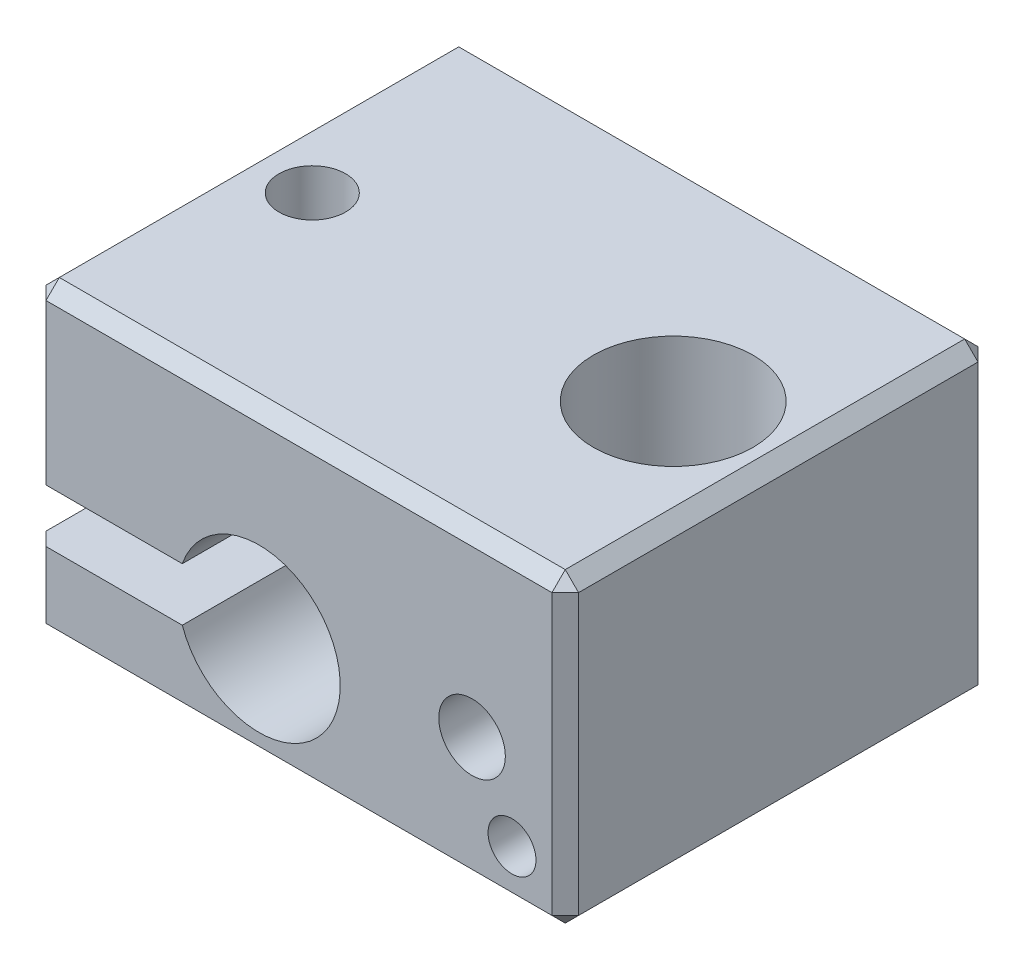
from build123d import *

# Parameters (mm, degrees)
BOSS_EXTRUDE1_DEPTH            = 8
CHAMFER1_SIZE                  = 0.5
M3X0_5_TAPPED_HOLE1_D          = 2.5
M3X0_5_TAPPED_HOLE1_DEPTH      = 3.5
M3X0_5_TAPPED_HOLE1_TIP        = 0.751075774
F_1_8_1_8_DIAMETER_HOLE1_D     = 1.8
F_1_8_1_8_DIAMETER_HOLE1_DEPTH = 2
F_1_8_1_8_DIAMETER_HOLE1_TIP   = 0.540774557
F_1_6_1_6_DIAMETER_HOLE1_D     = 1.6
F_1_6_1_6_DIAMETER_HOLE1_DEPTH = 4.5
F_1_6_1_6_DIAMETER_HOLE1_TIP   = 0.480688495
M3X0_5_TAPPED_HOLE2_D          = 2.5
M6X1_0_TAPPED_HOLE1_D          = 6


with BuildPart() as part:
    # Sketch1 → Boss-Extrude1 (new body, symmetric)
    with BuildSketch(Plane.XY):
        with BuildLine():
            Line((-10, -0.75), (-4.381405907, -0.75))
            ThreePointArc((-4.381405907, -0.75), (1.55, -1.75), (-4.381405907, -2.75))
            Line((-4.381405907, -2.75), (-10, -2.75))
            Line((-10, -2.75), (-10, -5.75))
            Line((-10, -5.75), (10, -5.75))
            Line((10, -5.75), (10, 5.75))
            Line((10, 5.75), (-10, 5.75))
            Line((-10, 5.75), (-10, -0.75))
        make_face()
    extrude(amount=BOSS_EXTRUDE1_DEPTH, both=True)

    # Chamfer1
    chamfer1_edges = [part.edges().sort_by_distance(p)[0] for p in [
        (-10, 2.5, 8),
        (0, 5.75, -8),
        (10, 0, -8),
        (10, -5.75, 0),
        (-10, -5.75, 0),
        (-10, 5.75, 0),
        (10, 5.75, 0),
        (-10, -4.25, 8),
        (0, -5.75, 8),
        (10, 0, 8),
        (0, 5.75, 8),
        (0, -5.75, -8),
        (-10, -4.25, -8),
        (-10, 2.5, -8),
    ]]
    chamfer(chamfer1_edges, length=CHAMFER1_SIZE)

    # M3x0.5 Tapped Hole1
    with Locations(Plane.XY.offset(8)):
        with Locations((6.5, -0.95)):
            Hole(M3X0_5_TAPPED_HOLE1_D / 2, depth=M3X0_5_TAPPED_HOLE1_DEPTH)
            with Locations((0, 0, -(M3X0_5_TAPPED_HOLE1_DEPTH + M3X0_5_TAPPED_HOLE1_TIP / 2))):  # 118° drill point
                Cone(0, M3X0_5_TAPPED_HOLE1_D / 2, M3X0_5_TAPPED_HOLE1_TIP, mode=Mode.SUBTRACT)

    # Ø1.8 (1.8) Diameter Hole1
    with Locations(Plane.XY.offset(8)):
        with Locations((8, -3.75)):
            Hole(F_1_8_1_8_DIAMETER_HOLE1_D / 2, depth=F_1_8_1_8_DIAMETER_HOLE1_DEPTH)
            with Locations((0, 0, -(F_1_8_1_8_DIAMETER_HOLE1_DEPTH + F_1_8_1_8_DIAMETER_HOLE1_TIP / 2))):  # 118° drill point
                Cone(0, F_1_8_1_8_DIAMETER_HOLE1_D / 2, F_1_8_1_8_DIAMETER_HOLE1_TIP, mode=Mode.SUBTRACT)

    # Ø1.6 (1.6) Diameter Hole1
    with Locations(Plane.XY.offset(8)):
        with Locations((8, -3.75)):
            Hole(F_1_6_1_6_DIAMETER_HOLE1_D / 2, depth=F_1_6_1_6_DIAMETER_HOLE1_DEPTH)
            with Locations((0, 0, -(F_1_6_1_6_DIAMETER_HOLE1_DEPTH + F_1_6_1_6_DIAMETER_HOLE1_TIP / 2))):  # 118° drill point
                Cone(0, F_1_6_1_6_DIAMETER_HOLE1_D / 2, F_1_6_1_6_DIAMETER_HOLE1_TIP, mode=Mode.SUBTRACT)

    # M3x0.5 Tapped Hole2 (through all)
    with Locations(Plane(origin=(0, 5.75, 0), x_dir=(1, 0, 0), z_dir=(0, 1, 0))):
        with Locations((-7.5, 0)):
            Hole(M3X0_5_TAPPED_HOLE2_D / 2)

    # M6x1.0 Tapped Hole1 (through all)
    with Locations(Plane(origin=(0, 5.75, 0), x_dir=(1, 0, 0), z_dir=(0, 1, 0))):
        with Locations((6.053799896, 0)):
            Hole(M6X1_0_TAPPED_HOLE1_D / 2)


solid = part.part
